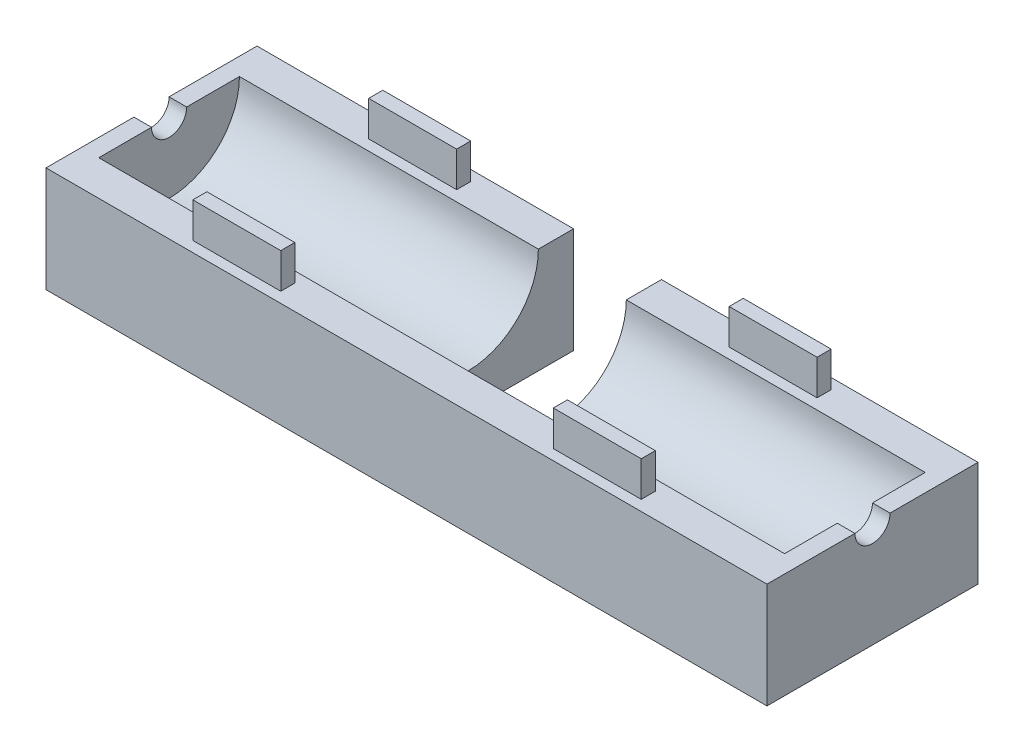
from build123d import *

# Parameters (mm, degrees)
BOSS_EXTRUDE2_DEPTH = 20.5
SKETCH4_W           = 5
SKETCH4_H           = 8.500741967
CUT_EXTRUDE1_DEPTH  = 45
BOSS_EXTRUDE4_DEPTH = 1
SKETCH3_W           = 5
SKETCH3_H           = 0.8
BOSS_EXTRUDE5_DEPTH = 2


with BuildPart() as part:
    # Sketch2 → Boss-Extrude2 (new body, symmetric)
    with BuildSketch(Plane(origin=(0, 0, 0), x_dir=(0, 0, -1), z_dir=(1, 0, 0))):
        with BuildLine():
            Line((-6, 6), (-4, 6))
            ThreePointArc((-4, 6), (0, 2), (4, 6))
            Line((4, 6), (6, 6))
            Line((6, 6), (6, 0))
            Line((6, 0), (-6, 0))
            Line((-6, 0), (-6, 6))
        make_face()
    extrude(amount=BOSS_EXTRUDE2_DEPTH, both=True)

    # Sketch4 → Cut-Extrude1 (cut)
    with BuildSketch(Plane.XZ):
        with Locations((0, -4.250370983)):
            Rectangle(SKETCH4_W, SKETCH4_H)
    extrude(amount=-CUT_EXTRUDE1_DEPTH, mode=Mode.SUBTRACT)

    # Sketch5 → Boss-Extrude4 (add)
    with BuildSketch(Plane.ZY.offset(20.5)):
        with BuildLine():
            Line((-4, 6), (-1, 6))
            ThreePointArc((-1, 6), (0, 5), (1, 6))
            Line((1, 6), (4, 6))
            ThreePointArc((4, 6), (0, 2), (-4, 6))
        make_face()
    boss_extrude4 = extrude(amount=-BOSS_EXTRUDE4_DEPTH)

    # Mirror1: Boss-Extrude4 across plane
    add(boss_extrude4.mirror(Plane(origin=(0, 0, 0), x_dir=(0, 0, 1), z_dir=(1, 0, 0))))

    # Sketch3 → Boss-Extrude5 (add)
    with BuildSketch(Plane(origin=(0, 6, 0), x_dir=(1, 0, 0), z_dir=(0, 1, 0))):
        with Locations((-10.25, 5)):
            Rectangle(SKETCH3_W, SKETCH3_H)
        with Locations((-10.25, -5)):
            Rectangle(SKETCH3_W, SKETCH3_H)
        with Locations((10.25, -5)):
            Rectangle(SKETCH3_W, SKETCH3_H)
        with Locations((10.25, 5)):
            Rectangle(SKETCH3_W, SKETCH3_H)
    extrude(amount=BOSS_EXTRUDE5_DEPTH)


solid = part.part
